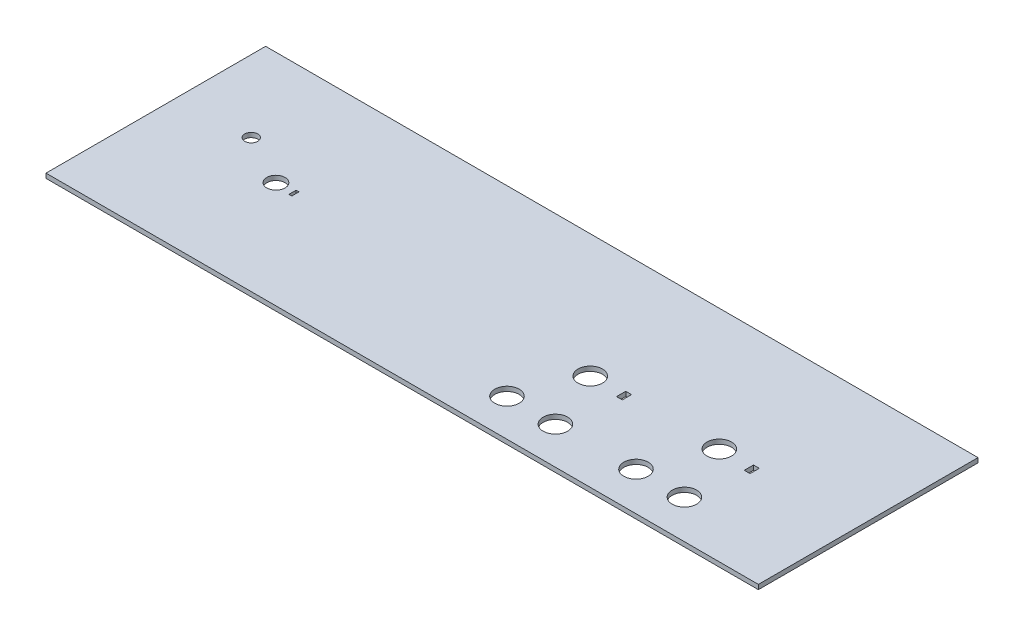
from build123d import *

# Parameters (mm, degrees)
SKETCH1_W           = 247.65
SKETCH1_H           = 76.3524
SKETCH1_R           = 4.25
SKETCH1_R_2         = 2.25
SKETCH1_R_3         = 3.175
SKETCH1_W_2         = 2
SKETCH1_H_2         = 3.2
SKETCH1_W_3         = 1
SKETCH1_H_3         = 2.5
BOSS_EXTRUDE1_DEPTH = 1.6


with BuildPart() as part:
    # Sketch1 → Boss-Extrude1 (new body)
    with BuildSketch(Plane(origin=(0, 0, 0), x_dir=(1, 0, 0), z_dir=(0, 1, 0))):
        with Locations((123.825, 38.1762)):
            Rectangle(SKETCH1_W, SKETCH1_H)
        with Locations(Location((208.518808658, 13.416643134, 0), (0, 0, 270))):  # turned: the seam where the file's is
            Circle(SKETCH1_R, mode=Mode.SUBTRACT)
        with Locations(Location((191.691308658, 13.416643134, 0), (0, 0, 270))):  # turned: the seam where the file's is
            Circle(SKETCH1_R, mode=Mode.SUBTRACT)
        with Locations(Location((164.119003876, 12.968247461, 0), (0, 0, 270))):  # turned: the seam where the file's is
            Circle(SKETCH1_R, mode=Mode.SUBTRACT)
        with Locations(Location((147.291503876, 12.968247461, 0), (0, 0, 270))):  # turned: the seam where the file's is
            Circle(SKETCH1_R, mode=Mode.SUBTRACT)
        with Locations(Location((200.105058658, 33.963274369, 0), (0, 0, 270))):  # turned: the seam where the file's is
            Circle(SKETCH1_R, mode=Mode.SUBTRACT)
        with Locations(Location((155.705253876, 33.49674194, 0), (0, 0, 270))):  # turned: the seam where the file's is
            Circle(SKETCH1_R, mode=Mode.SUBTRACT)
        with Locations(Location((25, 46.3524, 0), (0, 0, 270))):  # turned: the seam where the file's is
            Circle(SKETCH1_R_2, mode=Mode.SUBTRACT)
        with Locations(Location((42.853159836, 37.07576509, 0), (0, 0, 270))):  # turned: the seam where the file's is
            Circle(SKETCH1_R_3, mode=Mode.SUBTRACT)
        with Locations((211.855058658, 33.49674194)):
            Rectangle(SKETCH1_W_2, SKETCH1_H_2, mode=Mode.SUBTRACT)
        with Locations((167.455253876, 33.49674194)):
            Rectangle(SKETCH1_W_2, SKETCH1_H_2, mode=Mode.SUBTRACT)
        with Locations((49.128159836, 37.07576509)):
            Rectangle(SKETCH1_W_3, SKETCH1_H_3, mode=Mode.SUBTRACT)
    extrude(amount=BOSS_EXTRUDE1_DEPTH)


solid = part.part
